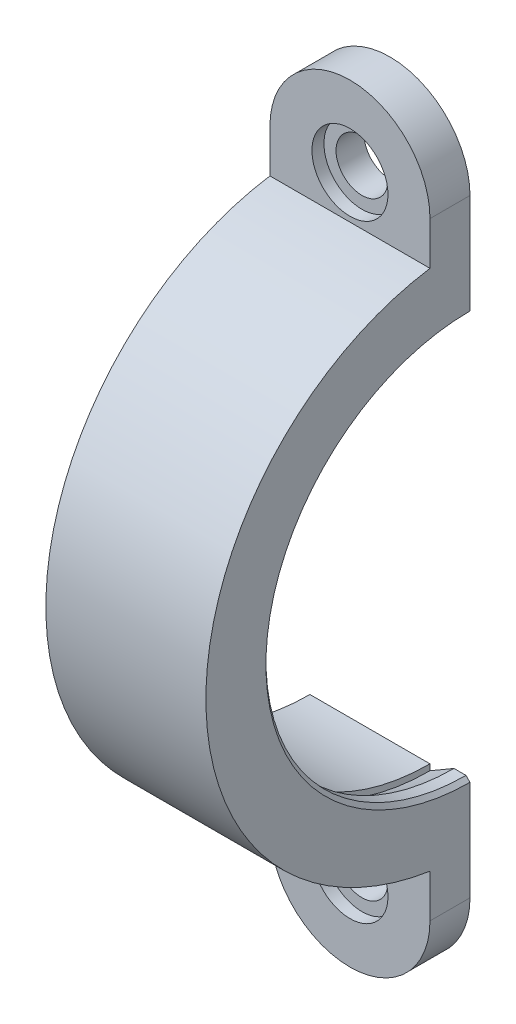
from build123d import *

# Parameters (mm, degrees)
REVOLVE1_ANGLE      = 180
BOSS_EXTRUDE3_DEPTH = 5
BOSS_EXTRUDE4_DEPTH = 5
SKETCH17_R          = 3.2385
CUT_EXTRUDE1_DEPTH  = 34
SKETCH18_R          = 4.75
CUT_EXTRUDE2_DEPTH  = 1.5
CHAMFER1_SIZE       = 0.5


with BuildPart() as part:
    # Sketch1 → Revolve1 (revolve)
    with BuildSketch(Plane.XY):
        Polygon((15, 26), (15, 26.75), (18, 25), (20, 25), (20, 33), (0, 33), (0, 26), align=None)
    revolve(axis=Axis((0, 0, 0), (1, 0, 0)), revolution_arc=REVOLVE1_ANGLE)

    # Sketch9 → Boss-Extrude3 (add)
    with BuildSketch(Plane(origin=(0, 0, 0), x_dir=(-1, 0, 0), z_dir=(0, 0, -1))):
        with BuildLine():
            Line((-20, 29), (0, 29))
            Line((0, 29), (0, 38))
            ThreePointArc((0, 38), (-10, 48), (-20, 38))
            Line((-20, 38), (-20, 29))
        make_face()
    extrude(amount=-BOSS_EXTRUDE3_DEPTH)

    # Sketch11 → Boss-Extrude4 (add)
    with BuildSketch(Plane(origin=(0, 0, 0), x_dir=(-1, 0, 0), z_dir=(0, 0, -1))):
        with BuildLine():
            Line((-20, -29), (0, -29))
            Line((0, -29), (0, -38))
            ThreePointArc((0, -38), (-10, -48), (-20, -38))
            Line((-20, -38), (-20, -29))
        make_face()
    extrude(amount=-BOSS_EXTRUDE4_DEPTH)

    # Sketch17 → Cut-Extrude1 (cut, through all)
    with BuildSketch(Plane(origin=(0, 0, 0), x_dir=(-1, 0, 0), z_dir=(0, 0, -1))):
        with Locations((-10, 38)):
            Circle(SKETCH17_R)
        with Locations((-10, -38)):
            Circle(SKETCH17_R)
    extrude(amount=-CUT_EXTRUDE1_DEPTH, mode=Mode.SUBTRACT)

    # Sketch18 → Cut-Extrude2 (cut)
    with BuildSketch(Plane.XY.offset(5)):
        with Locations((10, -38)):
            Circle(SKETCH18_R)
        with Locations((10, 38)):
            Circle(SKETCH18_R)
    extrude(amount=-CUT_EXTRUDE2_DEPTH, mode=Mode.SUBTRACT)

    # Chamfer1
    chamfer1_edges = [part.edges().sort_by_distance(p)[0] for p in [
        (20, 0, 25),
    ]]
    chamfer(chamfer1_edges, length=CHAMFER1_SIZE)


solid = part.part
